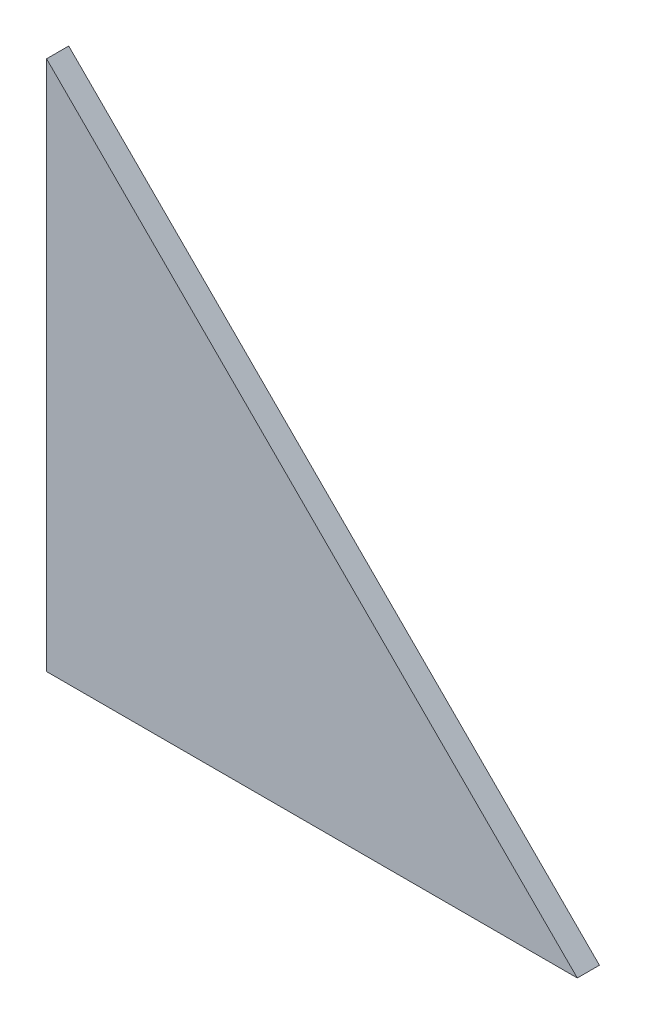
from build123d import *

# Parameters (mm, degrees)
BOSS_EXTRUDE1_DEPTH = 5


with BuildPart() as part:
    # Sketch1 → Boss-Extrude1 (new body)
    with BuildSketch(Plane.XY):
        Polygon((0, 0), (0, 120), (120, 0), align=None)
    extrude(amount=BOSS_EXTRUDE1_DEPTH)


solid = part.part
